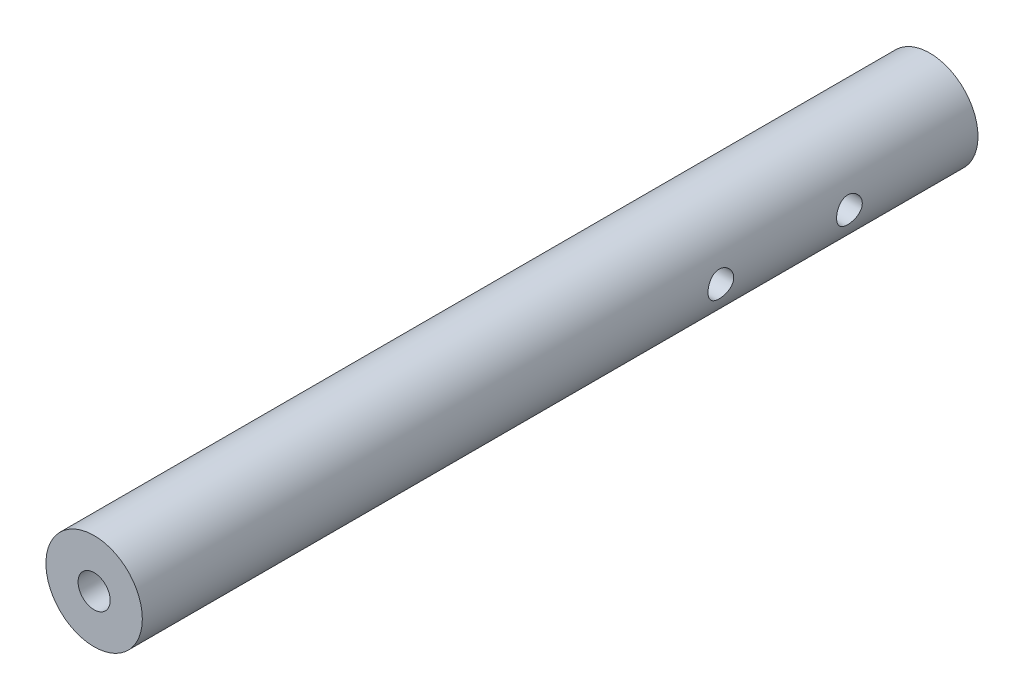
from build123d import *

# Parameters (mm, degrees)
SKETCH1_R           = 7.5
SKETCH1_R_2         = 2.5
BOSS_EXTRUDE1_DEPTH = 130
SKETCH2_R           = 2
CUT_EXTRUDE1_DEPTH  = 16


with BuildPart() as part:
    # Sketch1 → Boss-Extrude1 (new body)
    with BuildSketch(Plane.XY):
        Circle(SKETCH1_R)
        Circle(SKETCH1_R_2, mode=Mode.SUBTRACT)
    extrude(amount=BOSS_EXTRUDE1_DEPTH)

    # Sketch2 → Cut-Extrude1 (cut)
    with BuildSketch(Plane.ZY.offset(7.5)):
        with Locations((20, 0)):
            Circle(SKETCH2_R)
        with Locations((40, 0)):
            Circle(SKETCH2_R)
    extrude(amount=-CUT_EXTRUDE1_DEPTH, mode=Mode.SUBTRACT)


solid = part.part
